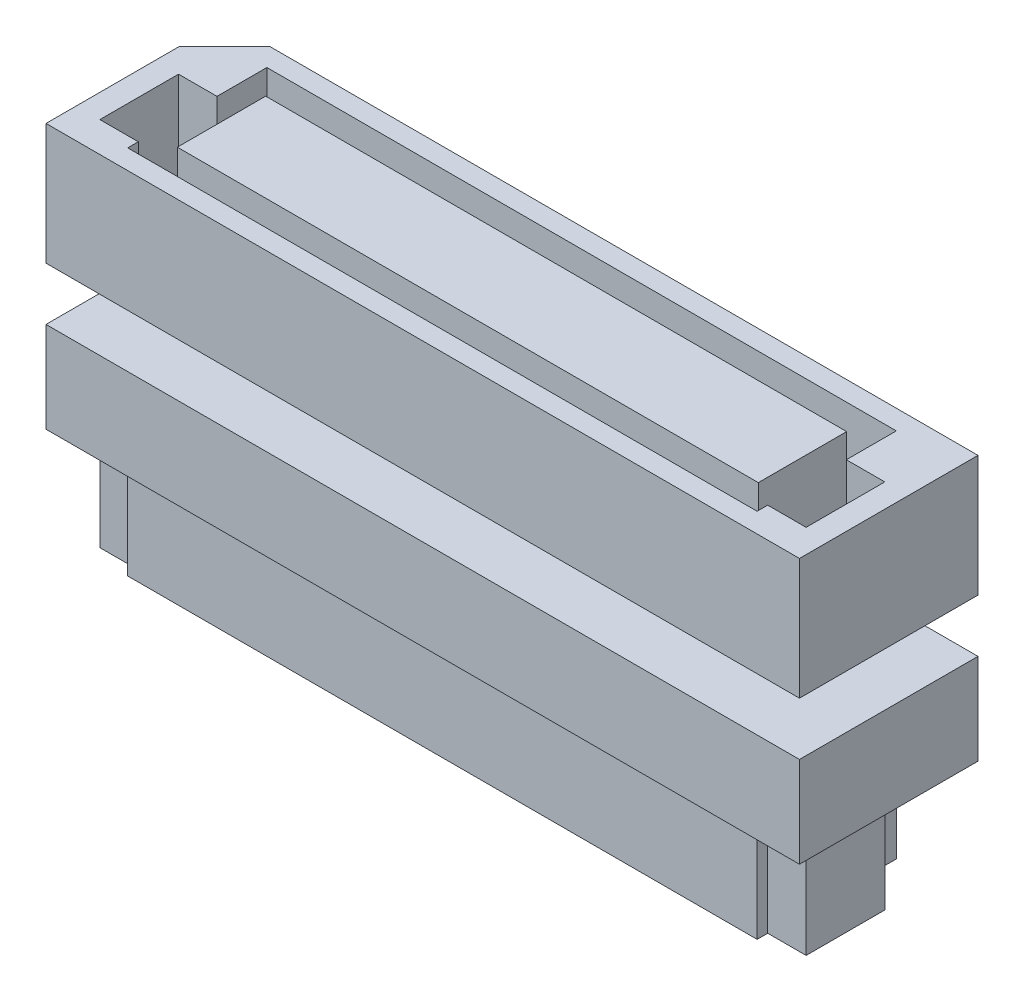
from build123d import *

# Parameters (mm, degrees)
SKETCH14_W          = 5.9
SKETCH14_H          = 4
BODY_DEPTH          = 12.45
SLOT_A_START        = -10.4
SKETCH17_W          = 4.6
SKETCH17_H          = 3.5
SLOT_A_DEPTH        = 11.4
SLOT_1_START        = -11.67
SKETCH18_W          = 2.6
SKETCH18_H          = 3.5
SLOT_1_DEPTH        = 12.67
BOSS_EXTRUDE3_START = -9.6
SKETCH23_W          = 2.92
SKETCH23_H          = 3.5
BOSS_EXTRUDE3_DEPTH = 9.6
CUT_EXTRUDE1_START  = -1.060820368
SKETCH19_W          = 12.908143914
SKETCH19_H          = 5.38442958
CUT_EXTRUDE1_DEPTH  = 2.060820368
BOSS_EXTRUDE1_DEPTH = 3
BOSS_EXTRUDE2_DEPTH = 3.5
SKETCH24_W          = 19.2
SKETCH24_H          = 2.92
CUT_EXTRUDE2_DEPTH  = 3.5


with BuildPart() as part:
    # Sketch14 → body (new body)
    with BuildSketch(Plane(origin=(0, 0, 0), x_dir=(0, 0, -1), z_dir=(1, 0, 0))):
        with Locations((0, 2)):
            Rectangle(SKETCH14_W, SKETCH14_H)
    extrude(amount=-BODY_DEPTH)

    # Sketch17 → slot-a (cut, through all)
    with BuildSketch(Plane(origin=(0, 0, 0), x_dir=(0, 0, -1), z_dir=(1, 0, 0)).offset(SLOT_A_START)):
        with Locations((0, 2.25)):
            Rectangle(SKETCH17_W, SKETCH17_H)
    extrude(amount=SLOT_A_DEPTH, mode=Mode.SUBTRACT)

    # Sketch18 → slot-1 (cut, through all)
    with BuildSketch(Plane(origin=(0, 0, 0), x_dir=(0, 0, -1), z_dir=(1, 0, 0)).offset(SLOT_1_START)):
        with Locations((-0.65, 2.25)):
            Rectangle(SKETCH18_W, SKETCH18_H)
    extrude(amount=SLOT_1_DEPTH, mode=Mode.SUBTRACT)

    # Sketch23 → Boss-Extrude3 (add)
    with BuildSketch(Plane(origin=(0, 0, 0), x_dir=(0, 0, -1), z_dir=(1, 0, 0)).offset(BOSS_EXTRUDE3_START)):
        with Locations((0, 2.25)):
            Rectangle(SKETCH23_W, SKETCH23_H)
    extrude(amount=BOSS_EXTRUDE3_DEPTH)

    # Mirror2: part across plane


with BuildPart() as part_1:
    add(part.part)
    add(part.part.mirror(Plane(origin=(0, 0, 0), x_dir=(0, 0, 1), z_dir=(1, 0, 0))))

    # Sketch19 → Cut-Extrude1 (cut, through all)
    with BuildSketch(Plane(origin=(-7.7, 0, -7.7), x_dir=(-0.707106781, 0, 0.707106781), z_dir=(-0.707106781, 0, -0.707106781)).offset(CUT_EXTRUDE1_START)):
        with Locations((10.2733597, 2.353779192)):
            Rectangle(SKETCH19_W, SKETCH19_H)
    extrude(amount=CUT_EXTRUDE1_DEPTH, mode=Mode.SUBTRACT)


with BuildPart() as body_2:
    # Sketch20 → Boss-Extrude1 (new body)
    with BuildSketch(Plane(origin=(0, -1.7526, 0), x_dir=(1, 0, 0), z_dir=(0, 1, 0))):
        Polygon((-12.45, -2.95), (-12.45, 1.449773449), (-10.949773449, 2.95), (12.45, 2.95), (12.45, -2.95), align=None)
    extrude(amount=-BOSS_EXTRUDE1_DEPTH)

    # Sketch22 → Boss-Extrude2 (add)
    with BuildSketch(Plane.XZ.offset(4.7526)):
        Polygon((10.4, 2.3), (10.4, 1.95), (11.67, 1.95), (11.67, -0.65), (10.4, -0.65), (10.4, -2.3), (-10.4, -2.3), (-10.4, -0.65), (-11.67, -0.65), (-11.67, 1.95), (-10.4, 1.95), (-10.4, 2.3), align=None)
    extrude(amount=BOSS_EXTRUDE2_DEPTH)

    # Sketch24 → Cut-Extrude2 (cut)
    with BuildSketch(Plane.XZ.offset(8.2526)):
        Rectangle(SKETCH24_W, SKETCH24_H)
    extrude(amount=-CUT_EXTRUDE2_DEPTH, mode=Mode.SUBTRACT)


solid = Compound([part_1.part, body_2.part])
